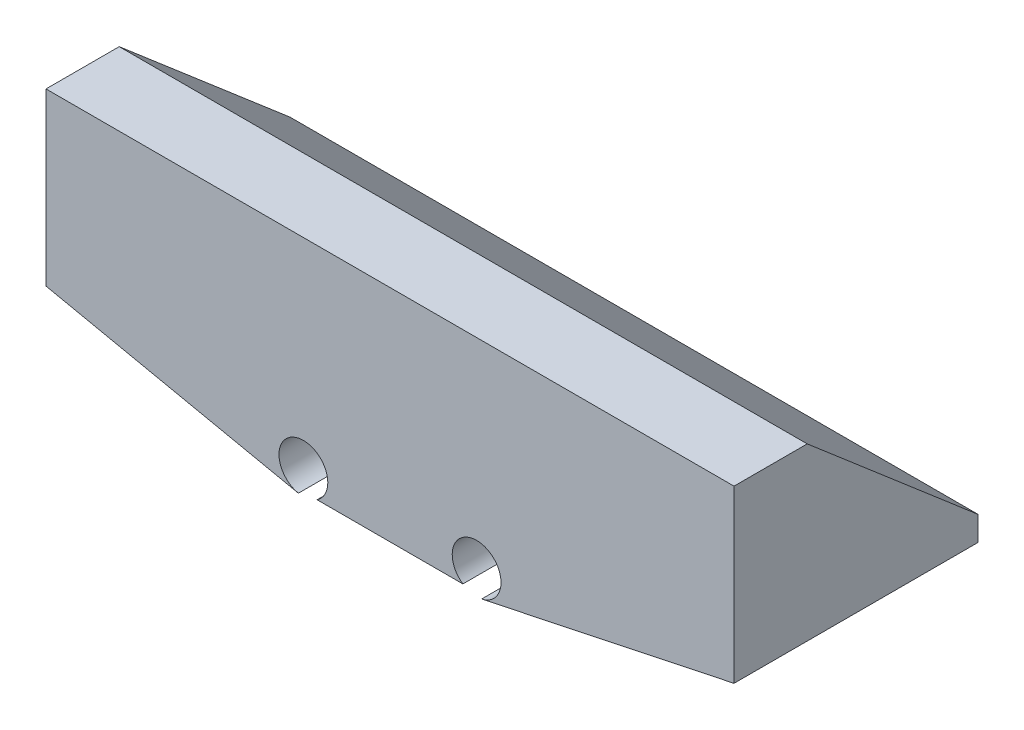
from build123d import *

# Parameters (mm, degrees)
BOSS_EXTRUDE1_DEPTH = 50
BOSS_EXTRUDE2_DEPTH = 140.997088


with BuildPart() as part:
    # Sketch2 → Boss-Extrude1 (new body)
    with BuildSketch(Plane.XY.offset(17)):
        with BuildLine():
            Line((70.444464788, 96.391350971), (18.723576719, 85.49867955))
            ThreePointArc((18.723576719, 85.49867955), (18.658589867, 95.297259441), (14.88570491, 86.253934263))
            Line((14.88570491, 86.253934263), (-14.993863644, 86.253934263))
            ThreePointArc((-14.993863644, 86.253934263), (-18.766748601, 95.297259441), (-18.831735453, 85.49867955))
            Line((-18.831735453, 85.49867955), (-70.552623522, 96.391350971))
            Line((-70.552623522, 96.391350971), (-70.552623522, 101.391350971))
            Line((-70.552623522, 101.391350971), (70.444464788, 101.391350971))
            Line((70.444464788, 101.391350971), (70.444464788, 96.391350971))
        make_face()
    extrude(amount=-BOSS_EXTRUDE1_DEPTH)

    # Sketch7 → Boss-Extrude2 (add)
    with BuildSketch(Plane.ZY.offset(70.552623522)):
        Polygon((17, 131.391350971), (2, 131.391350971), (-33, 101.391350971), (17, 101.391350971), align=None)
    extrude(amount=-BOSS_EXTRUDE2_DEPTH)


solid = part.part
